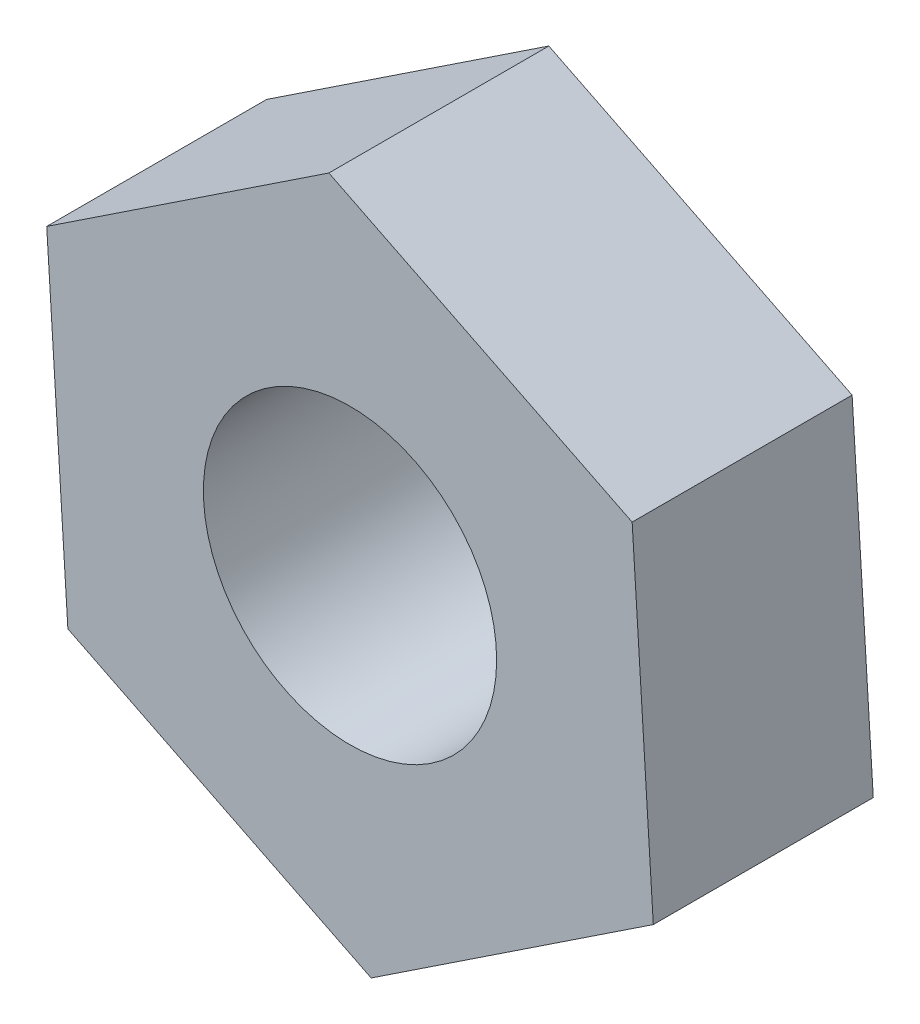
from build123d import *

# Parameters (mm, degrees)
BOSS_EXTRUDE1_DEPTH = 1.5
SKETCH2_R           = 1
CUT_EXTRUDE1_DEPTH  = 2.5


with BuildPart() as part:
    # Sketch1 → Boss-Extrude1 (new body)
    with BuildSketch(Plane.XY):
        Polygon((-1.923960579, -1.277383663), (0.144266413, -2.304890569), (2.068226992, -1.027506906), (1.923960579, 1.277383663), (-0.144266413, 2.304890569), (-2.068226992, 1.027506906), align=None)
    extrude(amount=BOSS_EXTRUDE1_DEPTH)

    # Sketch2 → Cut-Extrude1 (cut, through all)
    with BuildSketch(Plane.XY.offset(1.5)):
        Circle(SKETCH2_R)
    extrude(amount=-CUT_EXTRUDE1_DEPTH, mode=Mode.SUBTRACT)


solid = part.part
